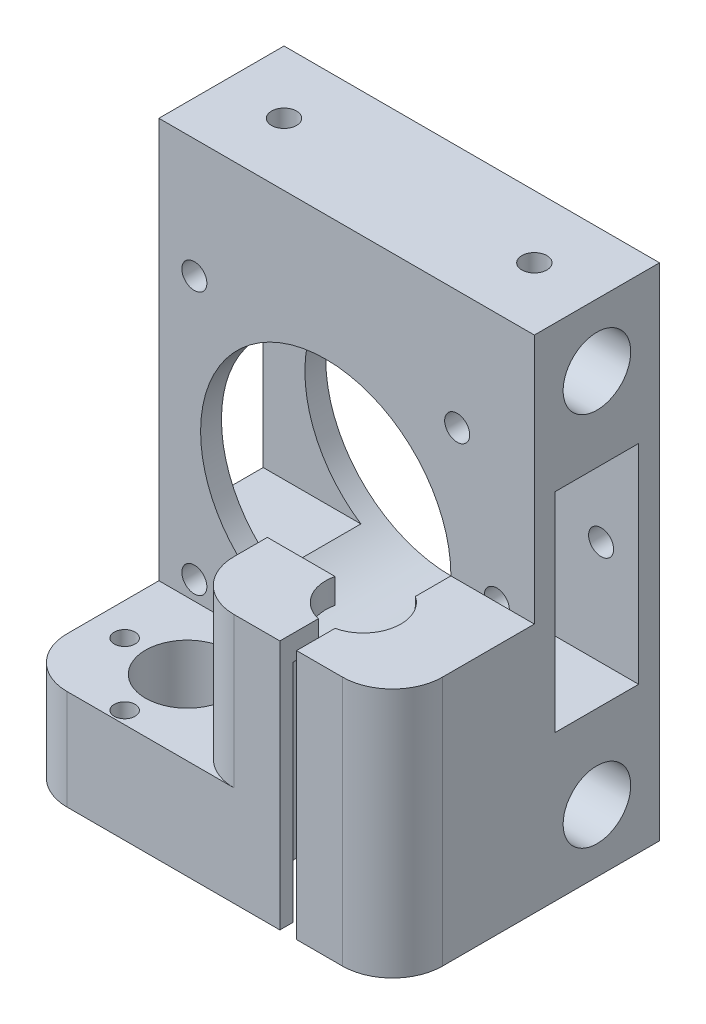
from build123d import *

# Parameters (mm, degrees)
SKETCH1_W           = 45
SKETCH1_H           = 60
BOSS_EXTRUDE1_DEPTH = 15
SKETCH2_R           = 4.05
SKETCH2_W           = 10
SKETCH2_H           = 25
CUT_EXTRUDE1_DEPTH  = 46
SKETCH3_W           = 17
SKETCH3_H           = 12
BOSS_EXTRUDE2_DEPTH = 45
SKETCH4_W           = 25
SKETCH4_H           = 17
BOSS_EXTRUDE3_DEPTH = 18
SKETCH5_W           = 2
SKETCH5_H           = 30
CUT_EXTRUDE2_DEPTH  = 5
SKETCH6_R           = 4.5
CUT_EXTRUDE3_DEPTH  = 61
SKETCH7_R           = 7.5
SKETCH7_R_2         = 5
SKETCH7_R_3         = 1.25
CUT_EXTRUDE4_DEPTH  = 27
SKETCH8_R           = 15
SKETCH8_R_2         = 1.5
CUT_EXTRUDE5_DEPTH  = 22
FILLET1_R           = 6
SKETCH9_R           = 1.5
CUT_EXTRUDE6_DEPTH  = 15
SKETCH10_R          = 1.5
CUT_EXTRUDE7_DEPTH  = 5
CUT_EXTRUDE8_START  = -60
SKETCH10_2_R        = 1.5
CUT_EXTRUDE8_DEPTH  = 5


with BuildPart() as part:
    # Sketch1 → Boss-Extrude1 (new body)
    with BuildSketch(Plane.XY):
        Rectangle(SKETCH1_W, SKETCH1_H)
    extrude(amount=BOSS_EXTRUDE1_DEPTH)

    # Sketch2 → Cut-Extrude1 (cut, through all)
    with BuildSketch(Plane(origin=(22.5, 0, 0), x_dir=(0, 0, -1), z_dir=(1, 0, 0))):
        with Locations((-7.5, 22.5)):
            Circle(SKETCH2_R)
        with Locations((-7.5, -22.5)):
            Circle(SKETCH2_R)
        with Locations((-7.5, 0)):
            Rectangle(SKETCH2_W, SKETCH2_H)
    extrude(amount=-CUT_EXTRUDE1_DEPTH, mode=Mode.SUBTRACT)

    # Sketch3 → Boss-Extrude2 (add)
    with BuildSketch(Plane.ZY.offset(22.5)):
        with Locations((23.5, -24)):
            Rectangle(SKETCH3_W, SKETCH3_H)
    extrude(amount=-BOSS_EXTRUDE2_DEPTH)

    # Sketch4 → Boss-Extrude3 (add)
    with BuildSketch(Plane(origin=(0, -18, 0), x_dir=(1, 0, 0), z_dir=(0, 1, 0))):
        with Locations((10, -23.5)):
            Rectangle(SKETCH4_W, SKETCH4_H)
    extrude(amount=BOSS_EXTRUDE3_DEPTH)

    # Sketch5 → Cut-Extrude2 (cut)
    with BuildSketch(Plane.XY.offset(32)):
        with Locations((10, -15)):
            Rectangle(SKETCH5_W, SKETCH5_H)
    extrude(amount=-CUT_EXTRUDE2_DEPTH, mode=Mode.SUBTRACT)

    # Sketch6 → Cut-Extrude3 (cut, through all)
    with BuildSketch(Plane.XZ.offset(30)):
        with Locations((10, 23)):
            Circle(SKETCH6_R)
    extrude(amount=-CUT_EXTRUDE3_DEPTH, mode=Mode.SUBTRACT)

    # Sketch7 → Cut-Extrude4 (cut)
    with BuildSketch(Plane.XZ.offset(30)):
        with Locations((10, 23)):
            Circle(SKETCH7_R)
        with Locations((-11.1, 23)):
            Circle(SKETCH7_R_2)
        with Locations((-3.6, 23)):
            Circle(SKETCH7_R_3)
        with Locations((-11.1, 30.5)):
            Circle(SKETCH7_R_3)
        with Locations((-11.1, 15.5)):
            Circle(SKETCH7_R_3)
        with Locations((-18.6, 23)):
            Circle(SKETCH7_R_3)
    extrude(amount=-CUT_EXTRUDE4_DEPTH, mode=Mode.SUBTRACT)

    # Sketch8 → Cut-Extrude5 (cut)
    with BuildSketch(Plane(origin=(0, 0, 0), x_dir=(-1, 0, 0), z_dir=(0, 0, -1))):
        with Locations((2.5, 0)):
            Circle(SKETCH8_R)
        with Locations((18.25, 15.75)):
            Circle(SKETCH8_R_2)
        with Locations((-13.25, 15.75)):
            Circle(SKETCH8_R_2)
        with Locations((-13.25, -15.75)):
            Circle(SKETCH8_R_2)
        with Locations((18.25, -15.75)):
            Circle(SKETCH8_R_2)
    extrude(amount=-CUT_EXTRUDE5_DEPTH, mode=Mode.SUBTRACT)

    # Fillet1
    fillet1_edges = [part.edges().sort_by_distance(p)[0] for p in [
        (-22.5, -24, 32),
        (-2.5, -9, 32),
        (22.5, -15, 32),
    ]]
    fillet(fillet1_edges, radius=FILLET1_R)

    # Sketch9 → Cut-Extrude6 (cut)
    with BuildSketch(Plane(origin=(0, 0, 0), x_dir=(-1, 0, 0), z_dir=(0, 0, -1))):
        with Locations((-18, 0)):
            Circle(SKETCH9_R)
    extrude(amount=-CUT_EXTRUDE6_DEPTH, mode=Mode.SUBTRACT)

    # Sketch10 → Cut-Extrude7 (cut)
    with BuildSketch(Plane(origin=(0, 30, 0), x_dir=(1, 0, 0), z_dir=(0, 1, 0))):
        with Locations((-15, -7.5)):
            Circle(SKETCH10_R)
        with Locations((15, -7.5)):
            Circle(SKETCH10_R)
    extrude(amount=-CUT_EXTRUDE7_DEPTH, mode=Mode.SUBTRACT)

    # Sketch10_2 → Cut-Extrude8 (cut)
    with BuildSketch(Plane(origin=(0, 30, 0), x_dir=(1, 0, 0), z_dir=(0, 1, 0)).offset(CUT_EXTRUDE8_START)):
        with Locations((-15, -7.5)):
            Circle(SKETCH10_2_R)
        with Locations((15, -7.5)):
            Circle(SKETCH10_2_R)
    extrude(amount=CUT_EXTRUDE8_DEPTH, mode=Mode.SUBTRACT)


solid = part.part
